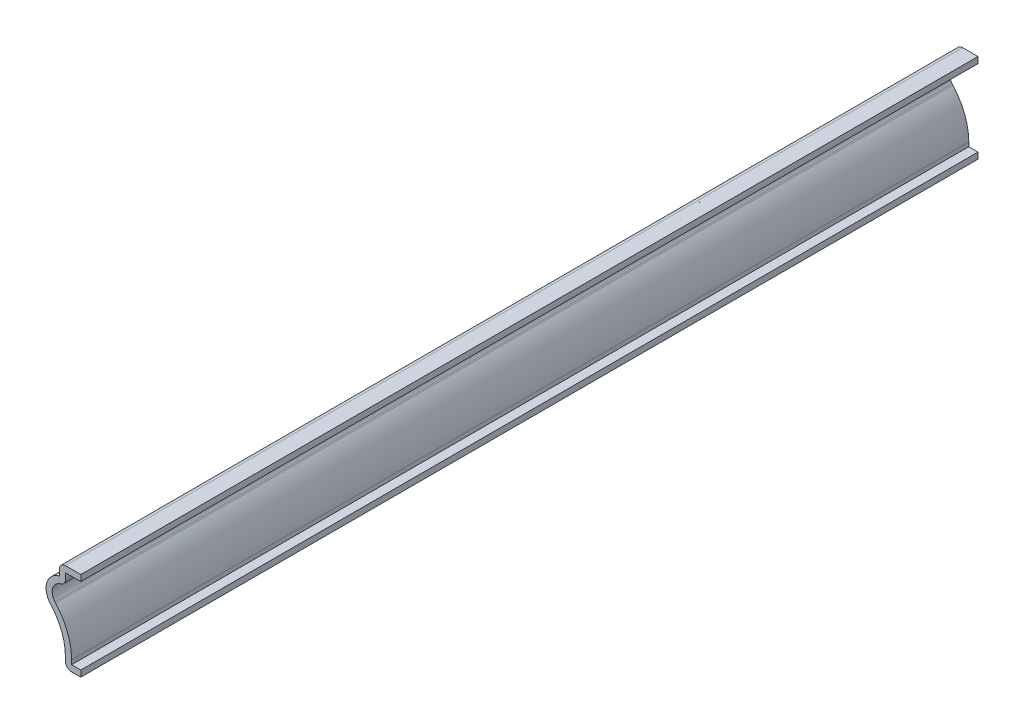
from build123d import *

# Parameters (mm, degrees)
EXTRUDE_THIN1_DEPTH = 184.15
FILLET1_R           = 1.27


with BuildPart() as part:
    # Sketch1 → Extrude-Thin1 (new body)
    with BuildSketch(Plane.XY):
        with BuildLine():
            Line((0, 0), (-3.163716198, 0))
            Line((-3.163716198, 0), (-3.163716198, 2.119463738))
            ThreePointArc((-3.163716198, 2.119463738), (-3.923538192, 6.196525566), (-6.100987039, 9.72618265))
            ThreePointArc((-6.100987039, 9.72618265), (-6.193680003, 9.830012941), (-6.284653862, 9.935352736))
            ThreePointArc((-6.284653862, 9.935352736), (-6.972873445, 13.371716383), (-4.421808228, 15.774695279))
            Line((-4.421808228, 15.774695279), (-4.421808228, 18.25625))
            Line((-4.421808228, 18.25625), (0, 18.25625))
            Line((0, 18.25625), (0, 16.98625))
            Line((0, 16.98625), (-3.151808228, 16.98625))
            Line((-3.151808228, 16.98625), (-3.151808228, 14.585167393))
            ThreePointArc((-3.151808228, 14.585167393), (-5.570244387, 13.426967033), (-5.316692669, 10.757515207))
            ThreePointArc((-5.316692669, 10.757515207), (-5.239362872, 10.667974045), (-5.160571796, 10.579715995))
            ThreePointArc((-5.160571796, 10.579715995), (-2.738796161, 6.654003785), (-1.893716198, 2.119463738))
            Line((-1.893716198, 2.119463738), (-1.893716198, 1.27))
            Line((-1.893716198, 1.27), (0, 1.27))
            Line((0, 1.27), (0, 0))
        make_face()
    extrude(amount=-EXTRUDE_THIN1_DEPTH)

    # Fillet1
    fillet1_edges = [part.edges().sort_by_distance(p)[0] for p in [
        (-3.163716198, 0, -92.075),
        (-4.421808228, 18.25625, -92.075),
        (-3.151808228, 14.585167393, -92.075),
    ]]
    fillet(fillet1_edges, radius=FILLET1_R)


solid = part.part
